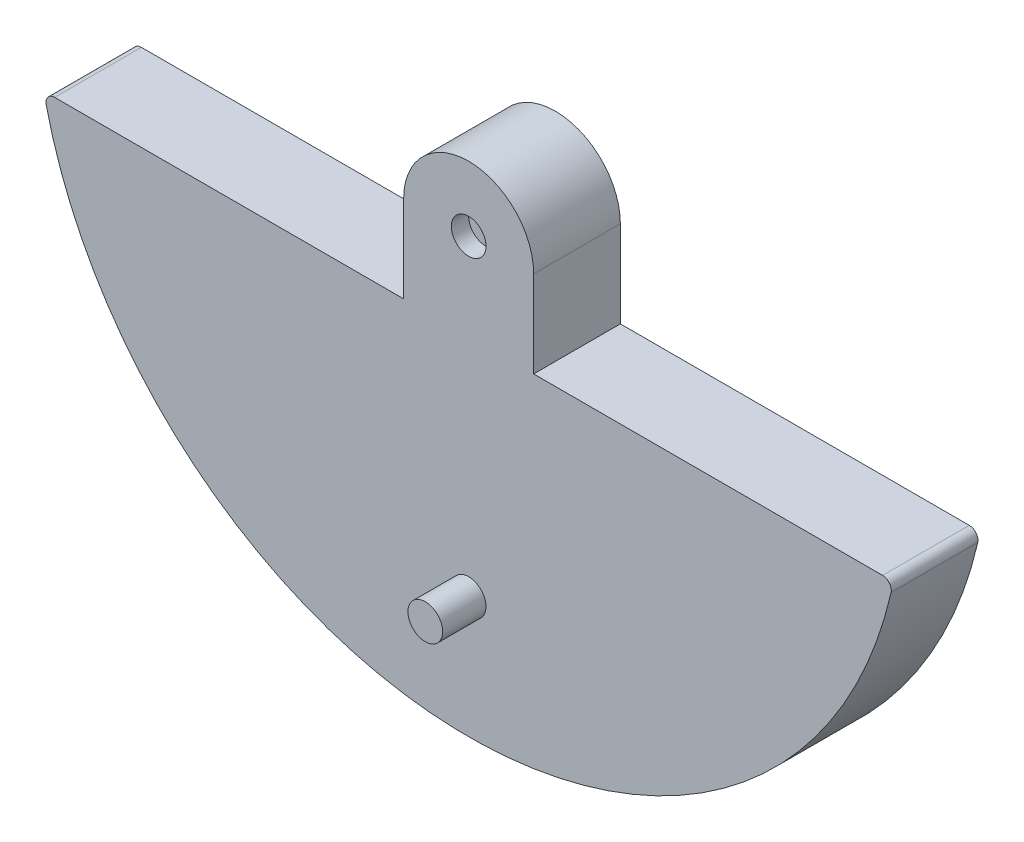
from build123d import *

# Parameters (mm, degrees)
BOSS_EXTRUDE1_DEPTH = 50
SKETCH2_R           = 10
CUT_EXTRUDE1_DEPTH  = 10
BOSS_EXTRUDE2_DEPTH = 50
FILLET1_R           = 5
SKETCH4_R           = 10
BOSS_EXTRUDE3_DEPTH = 25


with BuildPart() as part:
    # Sketch1 → Boss-Extrude1 (new body)
    with BuildSketch(Plane.XY):
        with BuildLine():
            Line((-37.5, 0), (-37.5, -100))
            Line((-37.5, -100), (37.5, -100))
            Line((37.5, -100), (37.5, 0))
            ThreePointArc((37.5, 0), (0, 37.5), (-37.5, 0))
        make_face()
    extrude(amount=BOSS_EXTRUDE1_DEPTH)

    # Sketch2 → Cut-Extrude1 (cut)
    with BuildSketch(Plane.XY.offset(50)):
        Circle(SKETCH2_R)
    extrude(amount=-CUT_EXTRUDE1_DEPTH, mode=Mode.SUBTRACT)

    # Sketch3 → Boss-Extrude2 (add)
    with BuildSketch(Plane.XY.offset(50)):
        with BuildLine():
            Line((-244.948974278, -50), (244.948974278, -50))
            ThreePointArc((244.948974278, -50), (0, -250), (-244.948974278, -50))
        make_face()
    extrude(amount=-BOSS_EXTRUDE2_DEPTH)

    # Fillet1
    fillet1_edges = [part.edges().sort_by_distance(p)[0] for p in [
        (-244.948974278, -50, 25),
        (244.948974278, -50, 25),
    ]]
    fillet(fillet1_edges, radius=FILLET1_R)


with BuildPart() as body_2:
    # Sketch4 → Boss-Extrude3 (new body)
    with BuildSketch(Plane.XY.offset(50)):
        with Locations((0, -180)):
            Circle(SKETCH4_R)
    extrude(amount=BOSS_EXTRUDE3_DEPTH)


solid = Compound([part.part, body_2.part])
